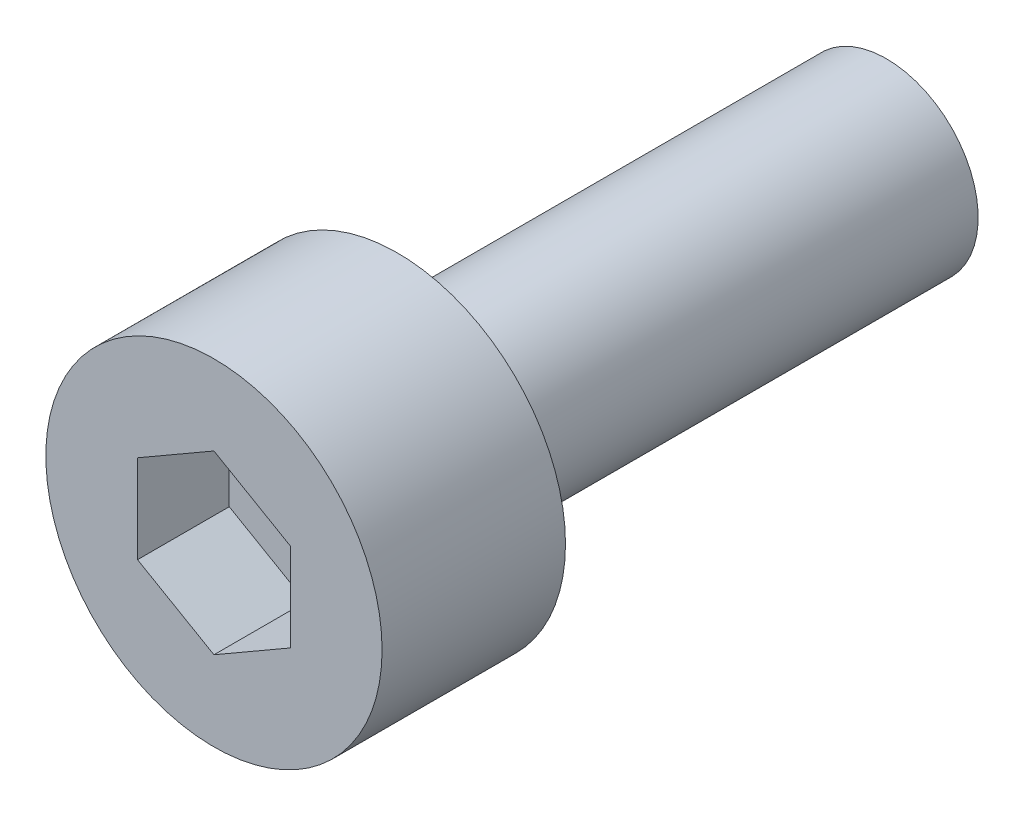
from build123d import *

# Parameters (mm, degrees)
SKETCH_1_R          = 2.75
EXTRUDE_1_DEPTH     = 3
CUT_EXTRUDE_1_DEPTH = 1.5
SKETCH_3_R          = 1.5
EXTRUDE_2_DEPTH     = 8


with BuildPart() as part:
    # 草图1 → 凸台-拉伸1 (new body)
    with BuildSketch(Plane.XY):
        Circle(SKETCH_1_R)
    extrude(amount=EXTRUDE_1_DEPTH)

    # 草图2 → 切除-拉伸1 (cut)
    with BuildSketch(Plane.XY.offset(3)):
        Polygon((0, -1.443375673), (1.25, -0.721687836), (1.25, 0.721687836), (0, 1.443375673), (-1.25, 0.721687836), (-1.25, -0.721687836), align=None)
    extrude(amount=-CUT_EXTRUDE_1_DEPTH, mode=Mode.SUBTRACT)

    # 草图3 → 凸台-拉伸2 (add)
    with BuildSketch(Plane(origin=(0, 0, 0), x_dir=(-1, 0, 0), z_dir=(0, 0, -1))):
        Circle(SKETCH_3_R)
    extrude(amount=EXTRUDE_2_DEPTH)


solid = part.part
